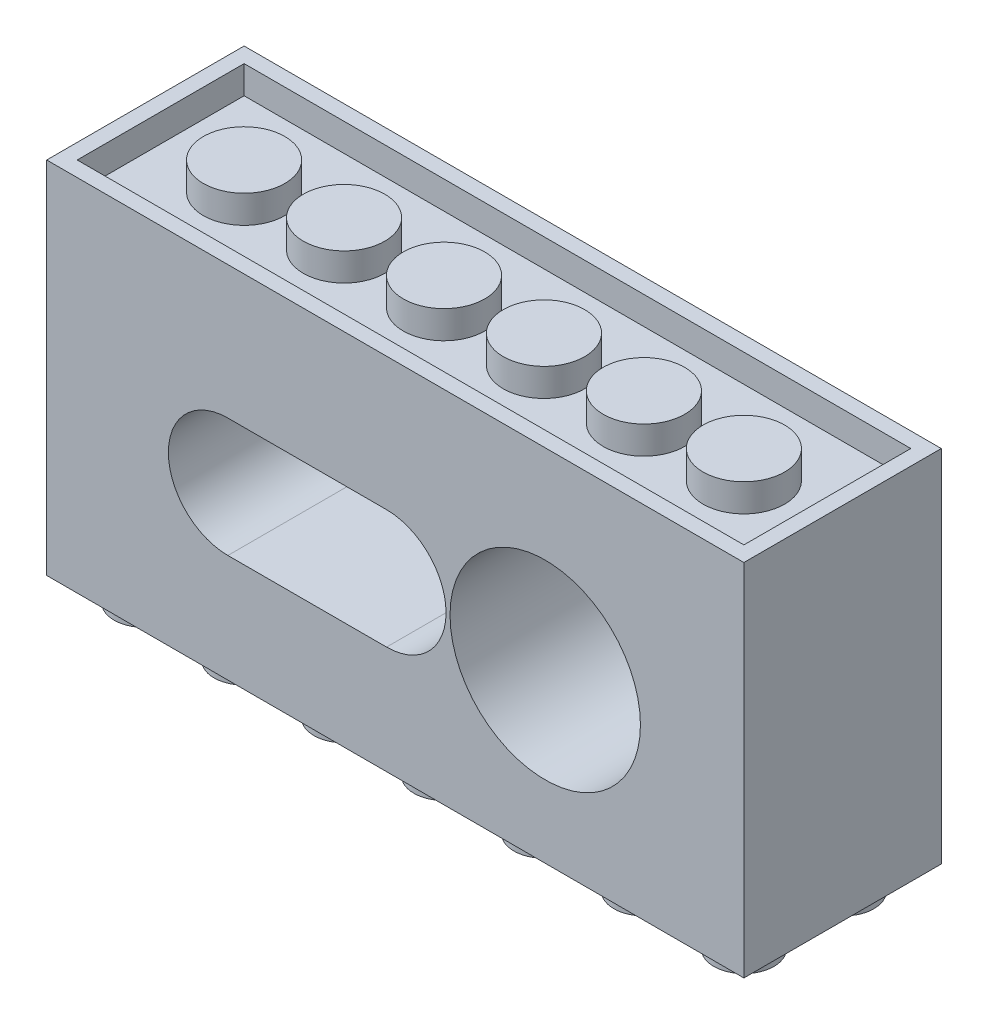
from build123d import *

# Parameters (mm, degrees)
SKETCH1_W           = 55.8
SKETCH1_H           = 15.8
BOSS_EXTRUDE1_DEPTH = 28.8
SKETCH2_R           = 7.62
CUT_EXTRUDE1_DEPTH  = 12.7
SKETCH4_R           = 2.778125
SKETCH4_R_2         = 1.8415
CUT_EXTRUDE2_DEPTH  = 12.7
CUT_EXTRUDE6_DEPTH  = 1.905
SKETCH8_W           = 53.36
SKETCH8_H           = 13.36
SKETCH8_R           = 3.26
CUT_EXTRUDE8_DEPTH  = 2.23
SKETCH11_R          = 2.405
BOSS_EXTRUDE3_DEPTH = 1.9


with BuildPart() as part:
    # Sketch1 → Boss-Extrude1 (new body)
    with BuildSketch(Plane(origin=(0, 0, 0), x_dir=(1, 0, 0), z_dir=(0, 1, 0))):
        with Locations((-11.199948696, 8.193463303)):
            Rectangle(SKETCH1_W, SKETCH1_H)
    extrude(amount=BOSS_EXTRUDE1_DEPTH)

    # Sketch2 → Cut-Extrude1 (cut)
    with BuildSketch(Plane.XY.offset(-0.293463303)):
        with Locations((0.800051304, 13.4)):
            Circle(SKETCH2_R)
        with BuildLine():
            Line((-11.899948696, 8.6375), (-24.599948696, 8.6375))
            ThreePointArc((-24.599948696, 8.6375), (-29.362448696, 13.4), (-24.599948696, 18.1625))
            Line((-24.599948696, 18.1625), (-11.899948696, 18.1625))
            ThreePointArc((-11.899948696, 18.1625), (-7.137448696, 13.4), (-11.899948696, 8.6375))
        make_face()
    extrude(amount=-CUT_EXTRUDE1_DEPTH, mode=Mode.SUBTRACT)

    # Sketch4 → Cut-Extrude2 (cut)
    with BuildSketch(Plane(origin=(0, 0, -16.093463303), x_dir=(-1, 0, 0), z_dir=(0, 0, -1))):
        with Locations((-0.800051304, 13.4)):
            Circle(SKETCH4_R)
        with Locations((11.899948696, 13.4)):
            Circle(SKETCH4_R_2)
        with Locations((24.599948696, 13.4)):
            Circle(SKETCH4_R_2)
    extrude(amount=-CUT_EXTRUDE2_DEPTH, mode=Mode.SUBTRACT)

    # Sketch5 → Cut-Extrude6 (cut)
    with BuildSketch(Plane(origin=(0, 0, -16.093463303), x_dir=(-1, 0, 0), z_dir=(0, 0, -1))):
        with BuildLine():
            Line((24.599948696, 18.1625), (11.899948696, 18.1625))
            ThreePointArc((11.899948696, 18.1625), (7.137448696, 13.4), (11.899948696, 8.6375))
            Line((11.899948696, 8.6375), (24.599948696, 8.6375))
            ThreePointArc((24.599948696, 8.6375), (29.362448696, 13.4), (24.599948696, 18.1625))
        make_face()
    extrude(amount=-CUT_EXTRUDE6_DEPTH, mode=Mode.SUBTRACT)

    # Sketch8 → Cut-Extrude8 (cut)
    with BuildSketch(Plane(origin=(0, 28.8, 0), x_dir=(1, 0, 0), z_dir=(0, 1, 0))):
        with Locations((-11.199948696, 8.193463303)):
            Rectangle(SKETCH8_W, SKETCH8_H)
        with Locations((-31.199948696, 8.193463303)):
            Circle(SKETCH8_R, mode=Mode.SUBTRACT)
        with Locations((-23.199948696, 8.193463303)):
            Circle(SKETCH8_R, mode=Mode.SUBTRACT)
        with Locations((-15.199948696, 8.193463303)):
            Circle(SKETCH8_R, mode=Mode.SUBTRACT)
        with Locations((-7.199948696, 8.193463303)):
            Circle(SKETCH8_R, mode=Mode.SUBTRACT)
        with Locations((0.800051304, 8.193463303)):
            Circle(SKETCH8_R, mode=Mode.SUBTRACT)
        with Locations((8.800051304, 8.193463303)):
            Circle(SKETCH8_R, mode=Mode.SUBTRACT)
    extrude(amount=-CUT_EXTRUDE8_DEPTH, mode=Mode.SUBTRACT)

    # Sketch11 → Boss-Extrude3 (add)
    with BuildSketch(Plane.XZ):
        with Locations((-35.199948696, -4.193463303)):
            Circle(SKETCH11_R)
        with Locations((-35.199948696, -12.193463303)):
            Circle(SKETCH11_R)
        with Locations((-27.199948696, -4.193463303)):
            Circle(SKETCH11_R)
        with Locations((-27.199948696, -12.193463303)):
            Circle(SKETCH11_R)
        with Locations((-19.199948696, -4.193463303)):
            Circle(SKETCH11_R)
        with Locations((-19.199948696, -12.193463303)):
            Circle(SKETCH11_R)
        with Locations((-11.199948696, -4.193463303)):
            Circle(SKETCH11_R)
        with Locations((-11.199948696, -12.193463303)):
            Circle(SKETCH11_R)
        with Locations((-3.199948696, -4.193463303)):
            Circle(SKETCH11_R)
        with Locations((-3.199948696, -12.193463303)):
            Circle(SKETCH11_R)
        with Locations((4.800051304, -4.193463303)):
            Circle(SKETCH11_R)
        with Locations((4.800051304, -12.193463303)):
            Circle(SKETCH11_R)
        with Locations((12.800051304, -4.193463303)):
            Circle(SKETCH11_R)
        with Locations((12.800051304, -12.193463303)):
            Circle(SKETCH11_R)
    extrude(amount=BOSS_EXTRUDE3_DEPTH)


solid = part.part
